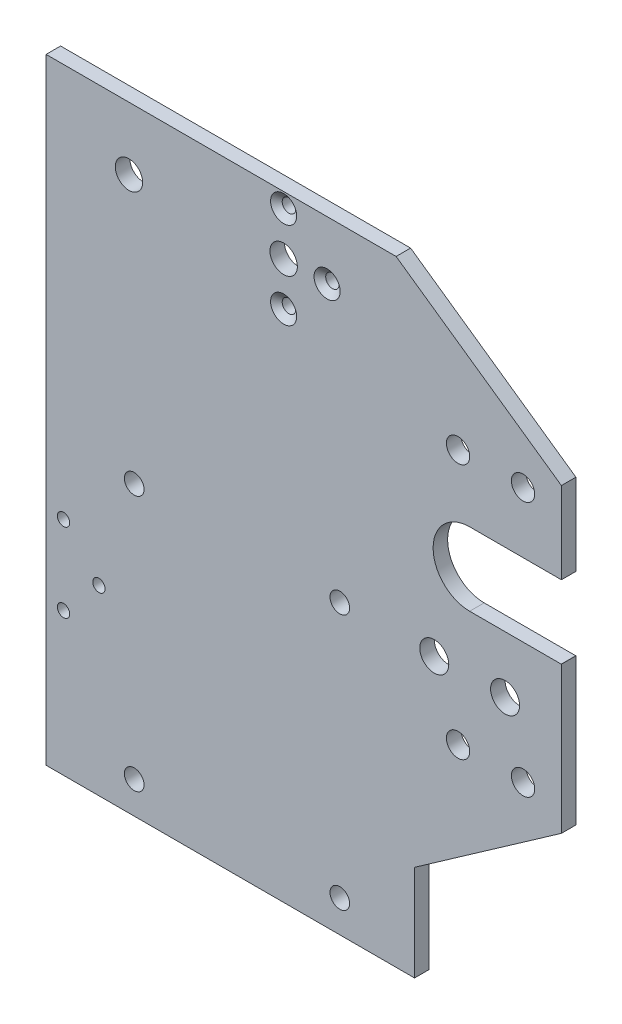
from build123d import *

# Parameters (mm, degrees)
BOSS_EXTRUDE1_DEPTH                               = 99.75
BOSS_EXTRUDE1_DEPTH_BACK                          = 35
SKETCH1_W                                         = 112.782
SKETCH1_H                                         = 3.175
CUT_EXTRUDE1_DEPTH                                = 129.830795468
CUT_EXTRUDE1_DEPTH_BACK                           = 129.830795468
SKETCH2_R                                         = 3.175
M4_CLEARANCE_HOLE1_D                              = 4.3
CSK_FOR_4_FLAT_HEAD_MACHINE_SCREW_100_D           = 2.9464
CSK_FOR_4_FLAT_HEAD_MACHINE_SCREW_100_CSINK_D     = 5.715
CSK_FOR_4_FLAT_HEAD_MACHINE_SCREW_100_CSINK_ANGLE = 100
SKETCH8_R                                         = 3
CUT_EXTRUDE3_DEPTH                                = 3.5
F_6_32_TAPPED_HOLE1_D                             = 2.7051
F_1_4_20_TAPPED_HOLE1_D                           = 5.1054
SKETCH16_R                                        = 2.9972
CUT_EXTRUDE4_DEPTH                                = 128.996890044


with BuildPart() as part:
    # Sketch1 → Boss-Extrude1 (new, two sides: drawn at the far end of the back side and taken through both)
    with BuildSketch(Plane(origin=(0, 0, 0), x_dir=(1, 0, 0), z_dir=(0, 1, 0)).offset(-BOSS_EXTRUDE1_DEPTH_BACK)):
        with Locations((23.753, -13.3875)):
            Rectangle(SKETCH1_W, SKETCH1_H)
    extrude(amount=BOSS_EXTRUDE1_DEPTH + BOSS_EXTRUDE1_DEPTH_BACK)

    # Sketch2 → Cut-Extrude1 (cut, two sides: drawn at the far end of the back side and taken through both)
    with BuildSketch(Plane.XY.offset(-CUT_EXTRUDE1_DEPTH_BACK)):
        with Locations((52.316, 28.127026218)):
            Circle(SKETCH2_R)
        with Locations((67.816, 28.127026218)):
            Circle(SKETCH2_R)
        Polygon((48, -35), (80.144, -35), (80.144, 8.487287802), (48, -14.020183306), align=None)
        with BuildLine():
            Line((60.066, 56.550419976), (80.066, 56.550419976))
            ThreePointArc((80.066, 56.550419976), (88.066, 48.550419976), (80.066, 40.550419976))
            Line((80.066, 40.550419976), (60.066, 40.550419976))
            ThreePointArc((60.066, 40.550419976), (52.066, 48.550419976), (60.066, 56.550419976))
        make_face()
        Polygon((43.964687276, 99.75), (80.144, 74.416972504), (80.144, 99.75), align=None)
    extrude(amount=CUT_EXTRUDE1_DEPTH + CUT_EXTRUDE1_DEPTH_BACK, mode=Mode.SUBTRACT)

    # M4 Clearance Hole1 (through all)
    with Locations(Plane.XY.offset(14.975)):
        with Locations((-13.356, 28), (31.644, 28), (31.644, -28), (-13.356, -28)):
            Hole(M4_CLEARANCE_HOLE1_D / 2)

    # CSK for _4 Flat Head Machine Screw _100 (through all)
    with Locations(Plane.XY.offset(14.975)):
        with Locations((19.352, 96.519071488), (28.871071488, 87), (19.352, 77.480928512)):
            CounterSinkHole(CSK_FOR_4_FLAT_HEAD_MACHINE_SCREW_100_D / 2, CSK_FOR_4_FLAT_HEAD_MACHINE_SCREW_100_CSINK_D / 2, counter_sink_angle=CSK_FOR_4_FLAT_HEAD_MACHINE_SCREW_100_CSINK_ANGLE)

    # Sketch8 → Cut-Extrude3 (cut)
    with BuildSketch(Plane.XY.offset(14.975)):
        with Locations((19.352, 87)):
            Circle(SKETCH8_R)
    extrude(amount=-CUT_EXTRUDE3_DEPTH, mode=Mode.SUBTRACT)

    # 6-32 Tapped Hole1 (through all)
    with Locations(Plane.XY.offset(14.975)):
        with Locations((-28.824, -3.758), (-21.077, 4.878), (-28.824, 13.514)):
            Hole(F_6_32_TAPPED_HOLE1_D / 2)

    # 1_4-20 Tapped Hole1 (through all)
    with Locations(Plane.XY.offset(14.975)):
        with Locations((57.526, 13.97), (71.75, 13.97), (71.75, 69.85), (57.526, 69.85)):
            Hole(F_1_4_20_TAPPED_HOLE1_D / 2)

    # Sketch16 → Cut-Extrude4 (cut, through all)
    with BuildSketch(Plane.XY.offset(14.975)):
        with Locations((-14.5061, 86.034)):
            Circle(SKETCH16_R)
    extrude(amount=-CUT_EXTRUDE4_DEPTH, mode=Mode.SUBTRACT)


solid = part.part
